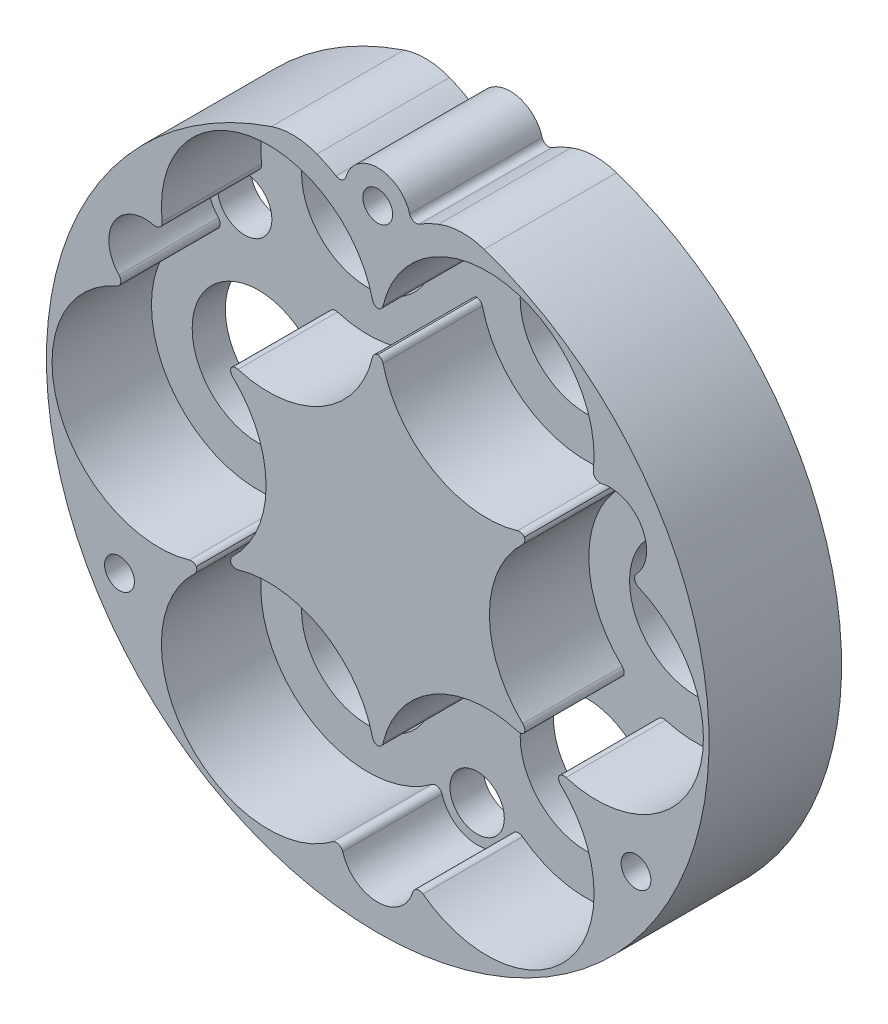
from build123d import *

# Parameters (mm, degrees)
EXTRUDE_1_DEPTH             = 20
CUT_EXTRUDE_1_DEPTH         = 15
EXTRUDE_2_DEPTH             = 15
HOLE_WIZARD_4_5_4_5_1_D     = 4.5
HOLE_WIZARD_4_5_4_5_1_DEPTH = 20
HOLE_WIZARD_20_0_20_1_D     = 20
HOLE_WIZARD_20_0_20_1_DEPTH = 20
HOLE_WIZARD_8_2_8_2_1_D     = 8.2
HOLE_WIZARD_8_2_8_2_1_DEPTH = 20
FILLET_1_R                  = 10


with BuildPart() as part:
    # 草图1 → 凸台-拉伸1 (new body)
    with BuildSketch(Plane(origin=(0, 0, 0), x_dir=(-1, 0, 0), z_dir=(0, 0, -1))):
        with BuildLine():
            ThreePointArc((-163.022889612, 198.274261736), (-150, 100), (-136.977110388, 198.274261736))
            ThreePointArc((-136.977110388, 198.274261736), (-140.459664046, 197.328853695), (-143.715646252, 195.773040012))
            ThreePointArc((-143.715646252, 195.773040012), (-144.596931613, 195.703918846), (-145.18869047, 196.36062508))
            ThreePointArc((-145.18869047, 196.36062508), (-150, 200), (-154.81130953, 196.36062508))
            ThreePointArc((-154.81130953, 196.36062508), (-155.403068387, 195.703918846), (-156.284353748, 195.773040012))
            ThreePointArc((-156.284353748, 195.773040012), (-159.540335954, 197.328853695), (-163.022889612, 198.274261736))
        make_face()
    extrude(amount=-EXTRUDE_1_DEPTH)

    # 草图2 → 切除-拉伸1 (cut)
    with BuildSketch(Plane.XY.offset(20)):
        with BuildLine():
            ThreePointArc((189.376148289, 164.838033327), (188.791059223, 165.557292987), (189.04835202, 166.448059))
            ThreePointArc((189.04835202, 166.448059), (189.837168574, 173), (183.768612947, 175.592835325))
            ThreePointArc((183.768612947, 175.592835325), (182.868540552, 175.815396233), (182.538187947, 176.681728058))
            ThreePointArc((182.538187947, 176.681728058), (169.336845119, 194.477731675), (150.795414997, 182.345602173))
            ThreePointArc((150.795414997, 182.345602173), (150.50949688, 181.851710417), (150, 181.594628396))
            ThreePointArc((150, 181.594628396), (149.49050312, 181.851710417), (149.204585003, 182.345602173))
            ThreePointArc((149.204585003, 182.345602173), (130.663154881, 194.477731675), (117.461812053, 176.681728058))
            ThreePointArc((117.461812053, 176.681728058), (117.131459448, 175.815396233), (116.231387053, 175.592835325))
            ThreePointArc((116.231387053, 175.592835325), (110.162831426, 173), (110.95164798, 166.448059))
            ThreePointArc((110.95164798, 166.448059), (111.208940777, 165.557292987), (110.623851711, 164.838033327))
            ThreePointArc((110.623851711, 164.838033327), (101.812731907, 144.507333265), (121.590179319, 134.516048507))
            ThreePointArc((121.590179319, 134.516048507), (122.160861185, 134.515382033), (122.638249186, 134.202685802))
            ThreePointArc((122.638249186, 134.202685802), (122.670358065, 133.63290755), (122.385594316, 133.138349319))
            ThreePointArc((122.385594316, 133.138349319), (121.149577026, 111.01493506), (143.162039659, 108.480238616))
            ThreePointArc((143.162039659, 108.480238616), (144.077481329, 108.62731078), (144.720260927, 107.959105675))
            ThreePointArc((144.720260927, 107.959105675), (150, 104), (155.279739073, 107.959105675))
            ThreePointArc((155.279739073, 107.959105675), (155.922518671, 108.62731078), (156.837960341, 108.480238616))
            ThreePointArc((156.837960341, 108.480238616), (178.850422974, 111.01493506), (177.614405684, 133.138349319))
            ThreePointArc((177.614405684, 133.138349319), (177.329641935, 133.63290755), (177.361750814, 134.202685802))
            ThreePointArc((177.361750814, 134.202685802), (177.839138815, 134.515382033), (178.409820681, 134.516048507))
            ThreePointArc((178.409820681, 134.516048507), (198.187268093, 144.507333265), (189.376148289, 164.838033327))
        make_face()
    extrude(amount=-CUT_EXTRUDE_1_DEPTH, mode=Mode.SUBTRACT)

    # 草图3 → 凸台-拉伸2 (add)
    with BuildSketch(Plane.XY.offset(5)):
        with BuildLine():
            ThreePointArc((150.795414997, 125.187925524), (150.50949688, 124.694033767), (150, 124.436951746))
            ThreePointArc((150, 124.436951746), (149.49050312, 124.694033767), (149.204585003, 125.187925524))
            ThreePointArc((149.204585003, 125.187925524), (141.575, 135.407471946), (128.909820681, 136.905113168))
            ThreePointArc((128.909820681, 136.905113168), (128.339138815, 136.905779642), (127.861750814, 137.218475873))
            ThreePointArc((127.861750814, 137.218475873), (127.829641935, 137.788254125), (128.114405684, 138.282812356))
            ThreePointArc((128.114405684, 138.282812356), (133.15, 150), (128.114405684, 161.717187644))
            ThreePointArc((128.114405684, 161.717187644), (127.829641935, 162.211745875), (127.861750814, 162.781524127))
            ThreePointArc((127.861750814, 162.781524127), (128.339138815, 163.094220358), (128.909820681, 163.094886832))
            ThreePointArc((128.909820681, 163.094886832), (141.575, 164.592528054), (149.204585003, 174.812074476))
            ThreePointArc((149.204585003, 174.812074476), (149.49050312, 175.305966233), (150, 175.563048254))
            ThreePointArc((150, 175.563048254), (150.50949688, 175.305966233), (150.795414997, 174.812074476))
            ThreePointArc((150.795414997, 174.812074476), (158.425, 164.592528054), (171.090179319, 163.094886832))
            ThreePointArc((171.090179319, 163.094886832), (171.660861185, 163.094220358), (172.138249186, 162.781524127))
            ThreePointArc((172.138249186, 162.781524127), (172.170358065, 162.211745875), (171.885594316, 161.717187644))
            ThreePointArc((171.885594316, 161.717187644), (166.85, 150), (171.885594316, 138.282812356))
            ThreePointArc((171.885594316, 138.282812356), (172.170358065, 137.788254125), (172.138249186, 137.218475873))
            ThreePointArc((172.138249186, 137.218475873), (171.660861185, 136.905779642), (171.090179319, 136.905113168))
            ThreePointArc((171.090179319, 136.905113168), (158.425, 135.407471946), (150.795414997, 125.187925524))
        make_face()
    extrude(amount=EXTRUDE_2_DEPTH)

    # Ø4.5 (4.5) 直径孔1
    with Locations(Plane(origin=(0, 0, 0), x_dir=(-1, 0, 0), z_dir=(0, 0, -1))):
        with Locations((-150, 195), (-111.02885683, 127.5), (-188.97114317, 127.5)):
            Hole(HOLE_WIZARD_4_5_4_5_1_D / 2, depth=HOLE_WIZARD_4_5_4_5_1_DEPTH)

    # Ø20.0 (20) 直径孔1
    with Locations(Plane(origin=(0, 0, 0), x_dir=(-1, 0, 0), z_dir=(0, 0, -1))):
        with Locations((-133.5, 178.578838325), (-117, 150), (-133.5, 121.421161675), (-166.5, 121.421161675), (-183, 150), (-166.5, 178.578838325)):
            Hole(HOLE_WIZARD_20_0_20_1_D / 2, depth=HOLE_WIZARD_20_0_20_1_DEPTH)

    # Ø8.2 (8.2) 直径孔1
    with Locations(Plane(origin=(0, 0, 0), x_dir=(-1, 0, 0), z_dir=(0, 0, -1))):
        with Locations((-114.925971147, 170.25), (-185.074028853, 170.25), (-150, 109.5)):
            Hole(HOLE_WIZARD_8_2_8_2_1_D / 2, depth=HOLE_WIZARD_8_2_8_2_1_DEPTH)

    # 圆角1
    fillet_1_edges = [part.edges().sort_by_distance(p)[0] for p in [
        (136.977110388, 198.274261736, 10),
        (163.022889612, 198.274261736, 10),
    ]]
    fillet(fillet_1_edges, radius=FILLET_1_R)


solid = part.part
